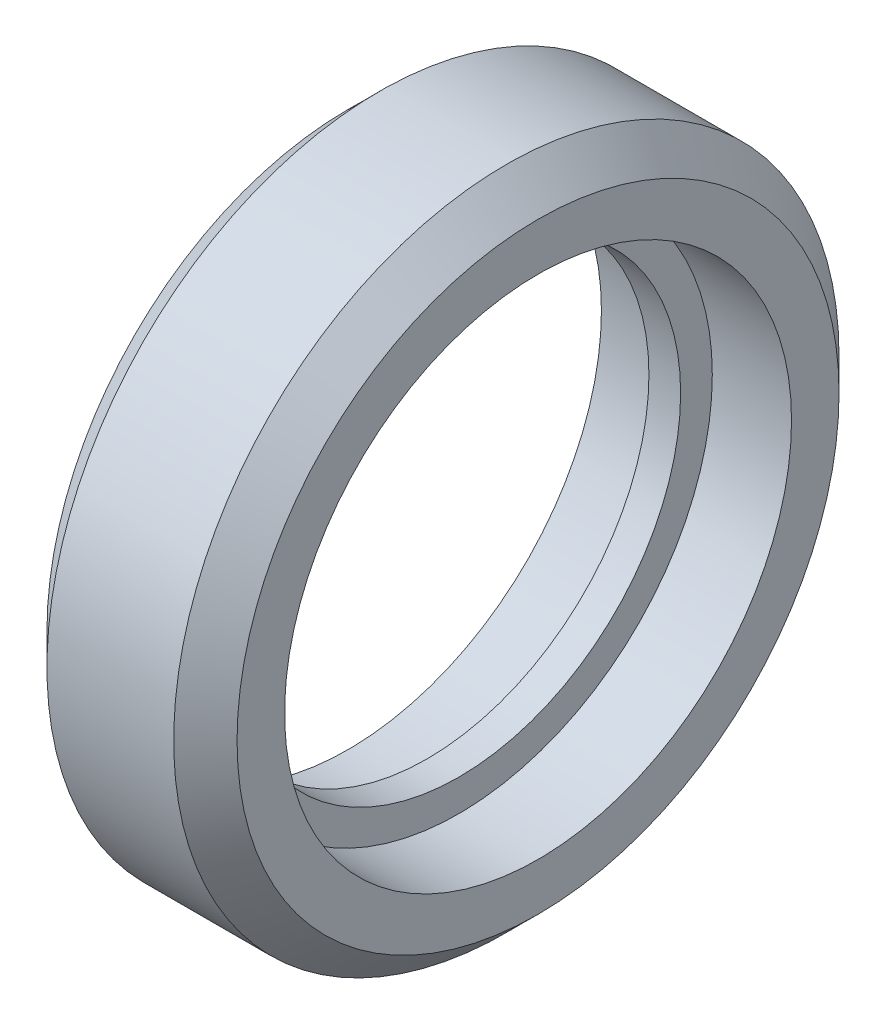
from build123d import *


with BuildPart() as part:
    # Sketch1 → Revolve1 (revolve)
    with BuildSketch(Plane.XY):
        Polygon((0, 7), (-0.5, 7), (-0.5, 8), (-3, 8), (-3, 9.5), (-2, 10.5), (0, 10.5), align=None)
    revolve1 = revolve(axis=Axis((0, 0, 0), (-1, 0, 0)))

    # Mirror1: Revolve1 across plane
    add(revolve1.mirror(Plane(origin=(0, 10.5, 0), x_dir=(0, 0, 1), z_dir=(1, 0, 0))))


solid = part.part
